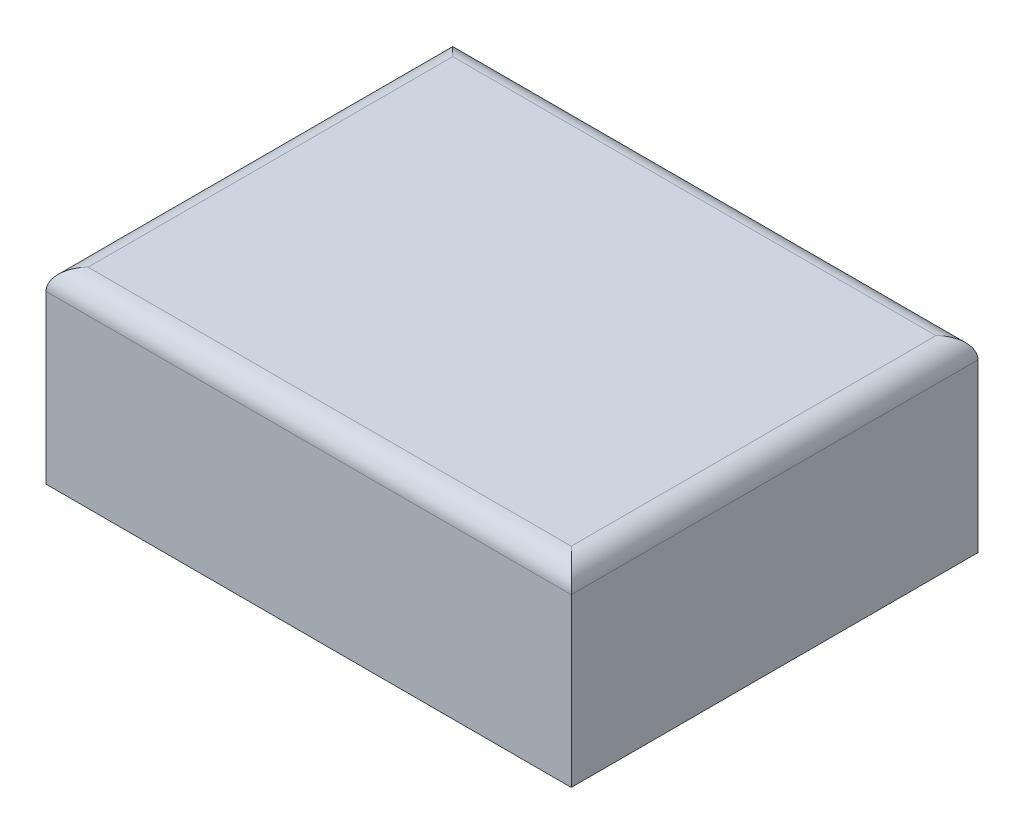
from build123d import *

# Parameters (mm, degrees)
SKETCH2_W           = 193.582912504
SKETCH2_H           = 89.448307966
BOSS_EXTRUDE1_DEPTH = 250
FILLET1_R           = 10


with BuildPart() as part:
    # Sketch2 → Boss-Extrude1 (new body)
    with BuildSketch(Plane.ZY.offset(265.404534045)):
        Rectangle(SKETCH2_W, SKETCH2_H)
    extrude(amount=BOSS_EXTRUDE1_DEPTH)

    # Fillet1
    fillet1_edges = [part.edges().sort_by_distance(p)[0] for p in [
        (-265.404534045, 44.724153983, 0),
        (-515.404534045, 44.724153983, 0),
        (-390.404534045, 44.724153983, -96.791456252),
        (-390.404534045, 44.724153983, 96.791456252),
    ]]
    fillet(fillet1_edges, radius=FILLET1_R)


solid = part.part
